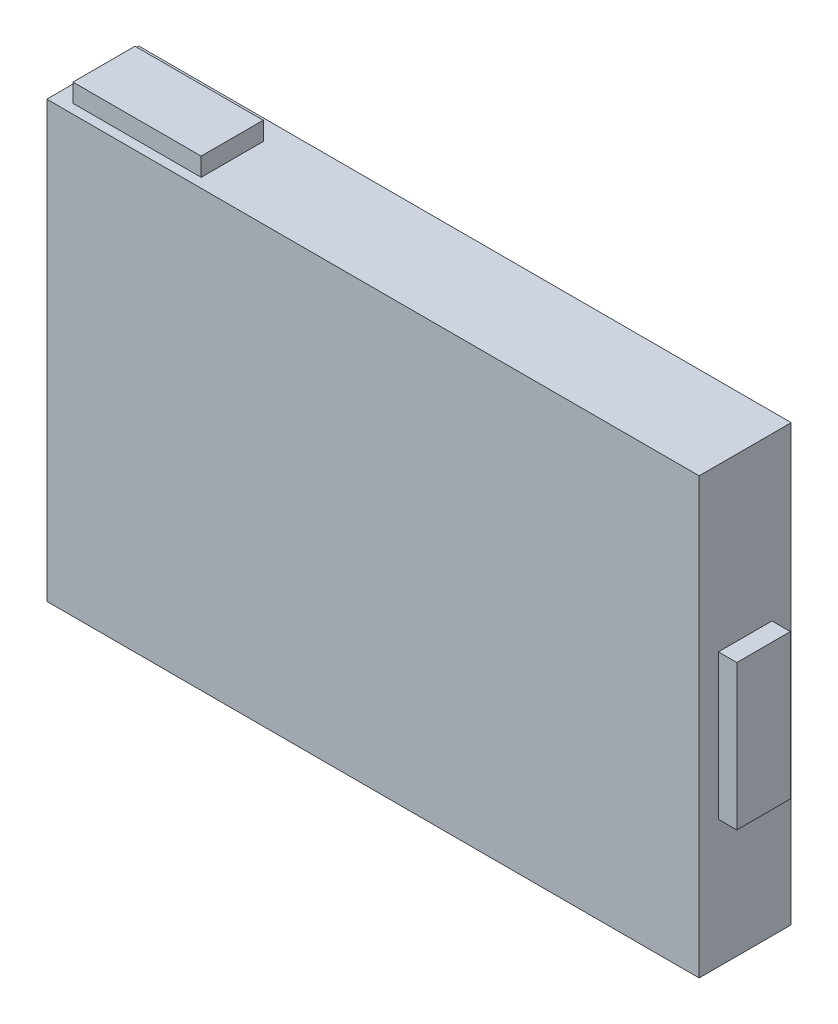
from build123d import *

# Parameters (mm, degrees)
SKETCH1_W           = 180
SKETCH1_H           = 120
BOSS_EXTRUDE2_DEPTH = 25.4
SKETCH2_W           = 165
SKETCH2_H           = 15.47592275
CUT_EXTRUDE2_DEPTH  = 25.4
SKETCH3_W           = 35.373537715
SKETCH3_H           = 17.134057331
CUT_EXTRUDE3_DEPTH  = 25.4
SKETCH4_W           = 14.782323972
SKETCH4_H           = 40
CUT_EXTRUDE4_DEPTH  = 25.4
SKETCH3_2_W         = 35.373537715
SKETCH3_2_H         = 17.134057331
BOSS_EXTRUDE3_DEPTH = 5.08
SKETCH4_2_W         = 14.782323972
SKETCH4_2_H         = 40
BOSS_EXTRUDE4_DEPTH = 5.08


with BuildPart() as part:
    # Sketch1 → Boss-Extrude2 (new body)
    with BuildSketch(Plane.XY):
        with Locations((0.791140914, 4.730009408)):
            Rectangle(SKETCH1_W, SKETCH1_H)
    extrude(amount=BOSS_EXTRUDE2_DEPTH)

    # Sketch2 → Cut-Extrude2 (cut)
    with BuildSketch(Plane.XZ.offset(55.269990592)):
        with Locations((0, 13.114533645)):
            Rectangle(SKETCH2_W, SKETCH2_H)
    extrude(amount=-CUT_EXTRUDE2_DEPTH, mode=Mode.SUBTRACT)

    # Sketch3 → Cut-Extrude3 (cut)
    with BuildSketch(Plane(origin=(0, 64.730009408, 0), x_dir=(1, 0, 0), z_dir=(0, 1, 0))):
        with Locations((-66.916021118, -14.219956699)):
            Rectangle(SKETCH3_W, SKETCH3_H)
    extrude(amount=-CUT_EXTRUDE3_DEPTH, mode=Mode.SUBTRACT)

    # Sketch4 → Cut-Extrude4 (cut)
    with BuildSketch(Plane(origin=(90.791140914, 0, 0), x_dir=(0, 0, -1), z_dir=(1, 0, 0))):
        with Locations((-12.7, 0)):
            Rectangle(SKETCH4_W, SKETCH4_H)
    extrude(amount=-CUT_EXTRUDE4_DEPTH, mode=Mode.SUBTRACT)


with BuildPart() as body_2:
    # Sketch3_2 → Boss-Extrude3 (new body)
    with BuildSketch(Plane(origin=(0, 64.730009408, 0), x_dir=(1, 0, 0), z_dir=(0, 1, 0))):
        with Locations((-66.916021118, -14.219956699)):
            Rectangle(SKETCH3_2_W, SKETCH3_2_H)
    extrude(amount=BOSS_EXTRUDE3_DEPTH)


with BuildPart() as body_3:
    # Sketch4_2 → Boss-Extrude4 (new body)
    with BuildSketch(Plane(origin=(90.791140914, 0, 0), x_dir=(0, 0, -1), z_dir=(1, 0, 0))):
        with Locations((-12.7, 0)):
            Rectangle(SKETCH4_2_W, SKETCH4_2_H)
    extrude(amount=BOSS_EXTRUDE4_DEPTH)


solid = Compound([part.part, body_2.part, body_3.part])
